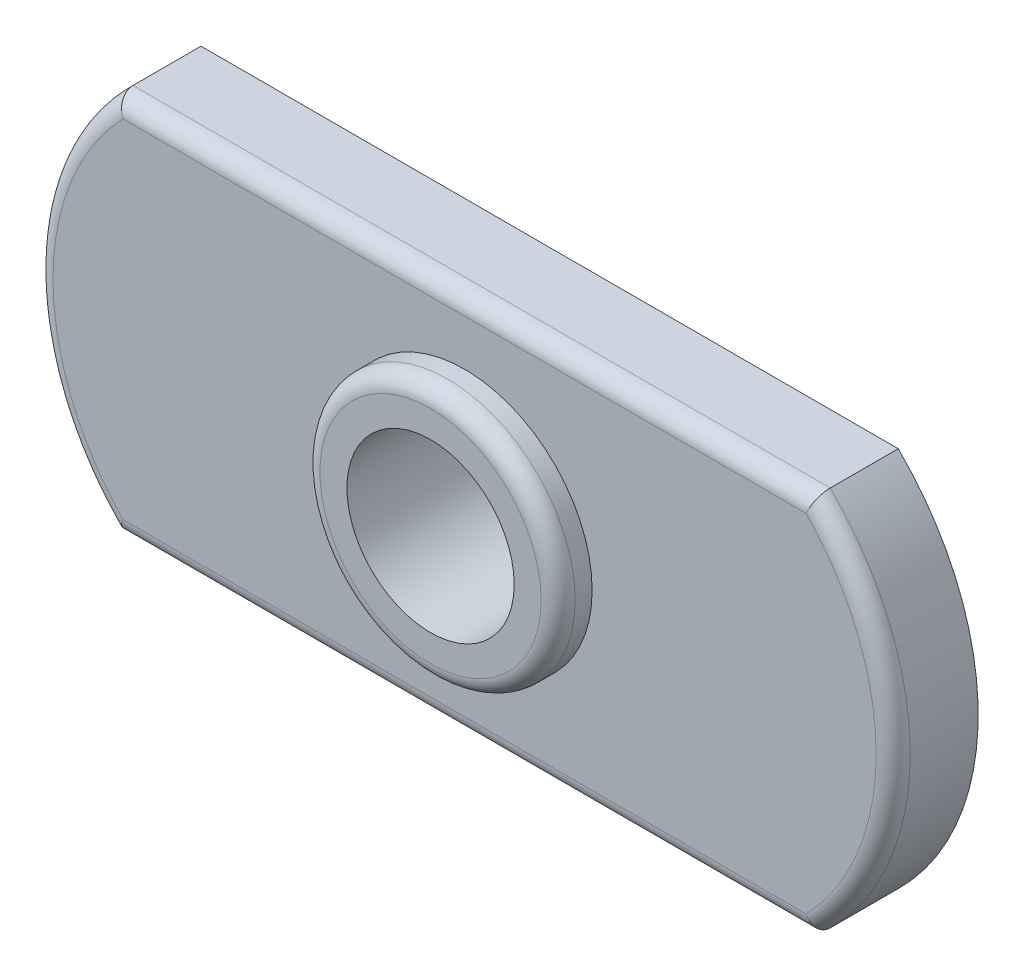
from build123d import *

# Parameters (mm, degrees)
EXTRUSION1_DEPTH = 2.5
SKETCH2_R        = 3.75
EXTRUSION2_DEPTH = 1
HOLE1_D          = 4.917
FILLET1_R        = 0.5


with BuildPart() as part:
    # Sketch1 → Extrusion1 (new body)
    with BuildSketch(Plane.XY):
        with BuildLine():
            Line((-10.25, -5.6), (10.25, -5.6))
            ThreePointArc((10.25, -5.6), (12.6, 0), (10.25, 5.6))
            Line((10.25, 5.6), (-10.25, 5.6))
            ThreePointArc((-10.25, 5.6), (-12.6, 0), (-10.25, -5.6))
        make_face()
    extrude(amount=EXTRUSION1_DEPTH)

    # Sketch2 → Extrusion2 (add)
    with BuildSketch(Plane.XY.offset(2.5)):
        Circle(SKETCH2_R)
    extrude(amount=EXTRUSION2_DEPTH)

    # Hole1 (through all)
    with Locations(Plane.XY.offset(3.5)):
        with Locations((0, 0)):
            Hole(HOLE1_D / 2)

    # Fillet1
    fillet1_edges = [part.edges().sort_by_distance(p)[0] for p in [
        (12.6, 0, 2.5),
        (0, 5.6, 2.5),
        (-3.75, 0, 3.5),
        (-12.6, 0, 2.5),
        (0, -5.6, 2.5),
    ]]
    fillet(fillet1_edges, radius=FILLET1_R)


solid = part.part
